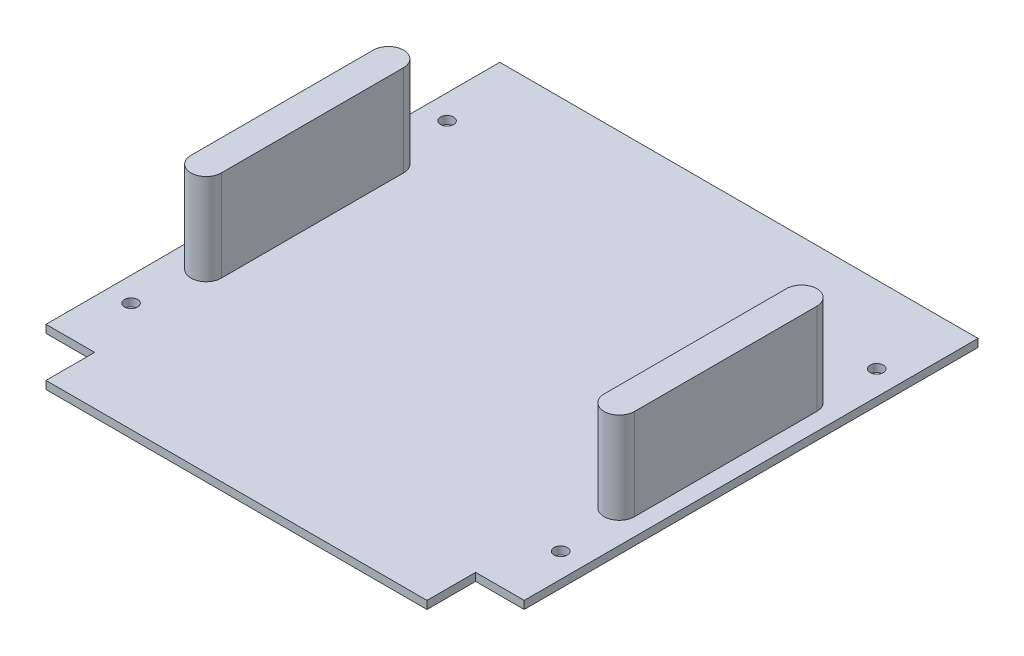
from build123d import *

# Parameters (mm, degrees)
BOSS_EXTRUDE1_DEPTH  = 3.302
BOSS_EXTRUDE2_DEPTH  = 38.1
M5_CLEARANCE_HOLE1_D = 5.5
SKETCH6_W            = 199.898
SKETCH6_H            = 3.302
BOSS_EXTRUDE3_DEPTH  = 1.62
SKETCH7_W            = 199.898
SKETCH7_H            = 3.302
BOSS_EXTRUDE4_DEPTH  = 5.18


with BuildPart() as part:
    # Sketch1 → Boss-Extrude1 (new body)
    with BuildSketch(Plane(origin=(0, 0, 0), x_dir=(1, 0, 0), z_dir=(0, 1, 0))):
        Polygon((99.949, -81.28), (99.949, 101.6), (-99.949, 101.6), (-99.949, -81.28), (-79.629, -81.28), (-79.629, -101.6), (79.629, -101.6), (79.629, -81.28), align=None)
    extrude(amount=BOSS_EXTRUDE1_DEPTH)

    # Sketch3 → Boss-Extrude2 (add)
    with BuildSketch(Plane(origin=(0, 3.302, 0), x_dir=(1, 0, 0), z_dir=(0, 1, 0))):
        with BuildLine():
            Line((92.71, 48.26), (92.71, -27.94))
            ThreePointArc((92.71, -27.94), (86.36, -34.29), (80.01, -27.94))
            Line((80.01, -27.94), (80.01, 48.26))
            ThreePointArc((80.01, 48.26), (86.36, 54.61), (92.71, 48.26))
        make_face()
        with BuildLine():
            Line((-80.01, 48.26), (-80.01, -27.94))
            ThreePointArc((-80.01, -27.94), (-86.36, -34.29), (-92.71, -27.94))
            Line((-92.71, -27.94), (-92.71, 48.26))
            ThreePointArc((-92.71, 48.26), (-86.36, 54.61), (-80.01, 48.26))
        make_face()
    extrude(amount=BOSS_EXTRUDE2_DEPTH)

    # M5 Clearance Hole1 (through all)
    with Locations(Plane(origin=(0, 3.302, 0), x_dir=(1, 0, 0), z_dir=(0, 1, 0))):
        with Locations((-89.789, -55.88), (-89.789, 76.2), (89.789, -55.88), (89.789, 76.2)):
            Hole(M5_CLEARANCE_HOLE1_D / 2)

    # Sketch6 → Boss-Extrude3 (add)
    with BuildSketch(Plane(origin=(0, 0, -101.6), x_dir=(-1, 0, 0), z_dir=(0, 0, -1))):
        with Locations((0, 1.651)):
            Rectangle(SKETCH6_W, SKETCH6_H)
    extrude(amount=BOSS_EXTRUDE3_DEPTH)

    # Sketch7 → Boss-Extrude4 (add)
    with BuildSketch(Plane(origin=(0, 0, -103.22), x_dir=(-1, 0, 0), z_dir=(0, 0, -1))):
        with Locations((0, 1.651)):
            Rectangle(SKETCH7_W, SKETCH7_H)
    extrude(amount=BOSS_EXTRUDE4_DEPTH)


solid = part.part
